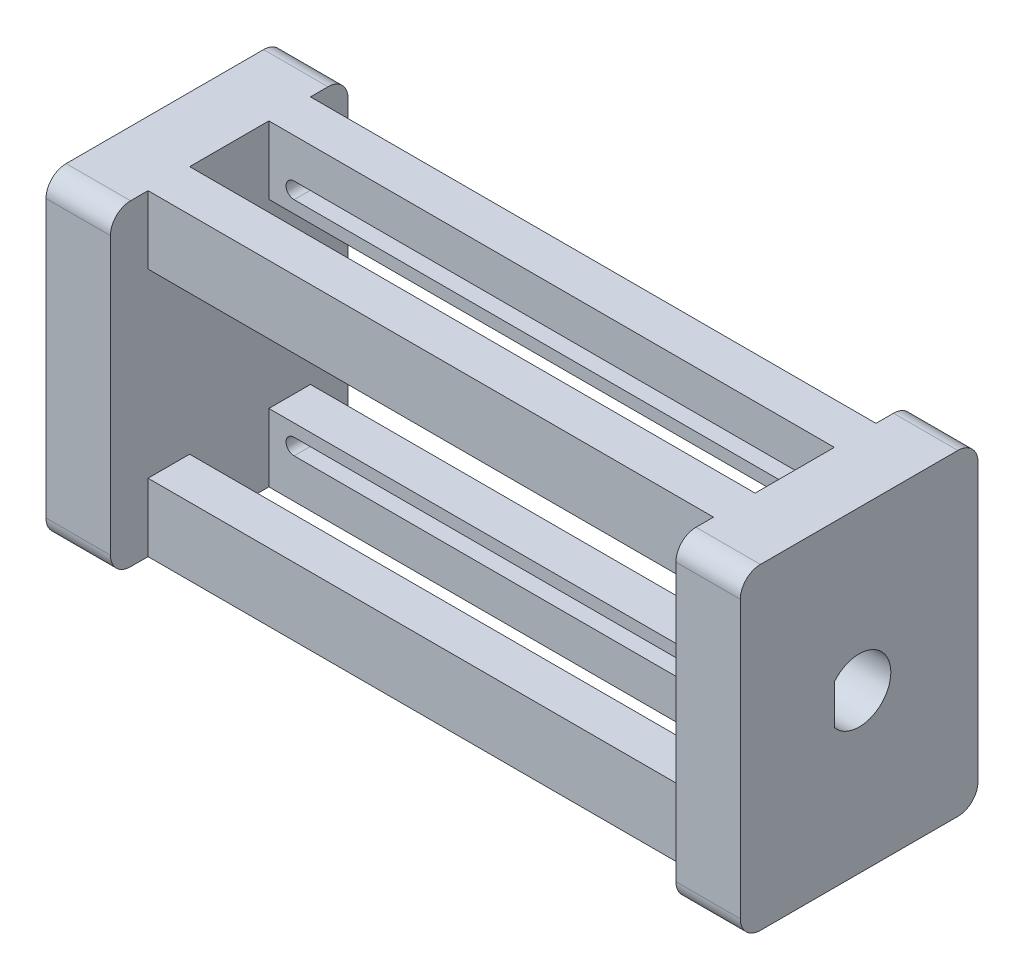
from build123d import *

# Parameters (mm, degrees)
SKETCH1_W               = 80
SKETCH1_H               = 40
BOSS_EXTRUDE1_DEPTH     = 20.5
SKETCH2_W               = 66.73316624
SKETCH2_H               = 22.854
CUT_EXTRUDE1_DEPTH      = 21.5
SKETCH3_W               = 30
SKETCH3_H               = 40
BOSS_EXTRUDE2_DEPTH     = 3.81
SKETCH4_R               = 4
CUT_EXTRUDE2_DEPTH      = 5.87375
SKETCH6_W               = 66.73316624
SKETCH6_H               = 10
CUT_EXTRUDE4_DEPTH      = 32.427
CUT_EXTRUDE4_DEPTH_BACK = 9.573
FILLET4_R               = 2.54
CUT_EXTRUDE5_DEPTH      = 5.25
BOSS_EXTRUDE3_DEPTH     = 5.87375
BOSS_EXTRUDE4_DEPTH     = 5.87375
CUT_EXTRUDE6_DEPTH      = 2.823417
CUT_EXTRUDE7_DEPTH      = 2.823417
BOSS_EXTRUDE5_DEPTH     = 0.508
BOSS_EXTRUDE6_DEPTH     = 0.508


with BuildPart() as part:
    # Sketch1 → Boss-Extrude1 (new body)
    with BuildSketch(Plane.XY):
        Rectangle(SKETCH1_W, SKETCH1_H)
    extrude(amount=BOSS_EXTRUDE1_DEPTH)

    # Sketch2 → Cut-Extrude1 (cut, through all)
    with BuildSketch(Plane.XY.offset(20.5)):
        Rectangle(SKETCH2_W, SKETCH2_H)
    extrude(amount=-CUT_EXTRUDE1_DEPTH, mode=Mode.SUBTRACT)

    # Sketch3 → Boss-Extrude2 (add, symmetric)
    with BuildSketch(Plane(origin=(40, 0, 0), x_dir=(0, 0, -1), z_dir=(1, 0, 0))):
        with Locations((-10.25, 0)):
            Rectangle(SKETCH3_W, SKETCH3_H)
    boss_extrude2 = extrude(amount=BOSS_EXTRUDE2_DEPTH, both=True)

    # Mirror1: Boss-Extrude2 across plane
    add(boss_extrude2.mirror(Plane(origin=(0, 0, 0), x_dir=(0, 0, 1), z_dir=(1, 0, 0))))

    # Sketch4 → Cut-Extrude2 (cut)
    with BuildSketch(Plane(origin=(43.81, 0, 0), x_dir=(0, 0, -1), z_dir=(1, 0, 0))):
        with Locations((-10.25, 0)):
            Circle(SKETCH4_R)
    cut_extrude2 = extrude(amount=-CUT_EXTRUDE2_DEPTH, mode=Mode.SUBTRACT)

    # Mirror2: Cut-Extrude2 across plane
    add(cut_extrude2.mirror(Plane(origin=(0, 0, 0), x_dir=(0, 0, 1), z_dir=(1, 0, 0))), mode=Mode.SUBTRACT)

    # Sketch6 → Cut-Extrude4 (cut, two sides)
    with BuildSketch(Plane(origin=(0, -11.427, 0), x_dir=(1, 0, 0), z_dir=(0, 1, 0))) as cut_extrude4_sk:
        with Locations((0, -10.25)):
            Rectangle(SKETCH6_W, SKETCH6_H)
    extrude(amount=CUT_EXTRUDE4_DEPTH, mode=Mode.SUBTRACT)
    extrude(cut_extrude4_sk.sketch, amount=-CUT_EXTRUDE4_DEPTH_BACK, mode=Mode.SUBTRACT)

    # Fillet4
    fillet4_edges = [part.edges().sort_by_distance(p)[0] for p in [
        (40, 20, 25.25),
        (40, -20, 25.25),
        (40, -20, -4.75),
        (40, 20, -4.75),
        (-40, -20, 25.25),
        (-40, 20, 25.25),
        (-40, 20, -4.75),
        (-40, -20, -4.75),
    ]]
    fillet(fillet4_edges, radius=FILLET4_R)

    # Sketch7 → Cut-Extrude5 (cut)
    with BuildSketch(Plane(origin=(0, 0, 0), x_dir=(-1, 0, 0), z_dir=(0, 0, -1))):
        with BuildLine():
            Line((-32.5, 15.016), (32.5, 15.016))
            ThreePointArc((32.5, 15.016), (33.516, 14), (32.5, 12.984))
            Line((32.5, 12.984), (-32.5, 12.984))
            ThreePointArc((-32.5, 12.984), (-33.516, 14), (-32.5, 15.016))
        make_face()
    cut_extrude5 = extrude(amount=-CUT_EXTRUDE5_DEPTH, mode=Mode.SUBTRACT)

    # Mirror3: Cut-Extrude5 across plane
    add(cut_extrude5.mirror(Plane.ZX), mode=Mode.SUBTRACT)

    # Sketch8 → Boss-Extrude3 (add)
    with BuildSketch(Plane(origin=(43.81, 0, 0), x_dir=(0, 0, -1), z_dir=(1, 0, 0))):
        with BuildLine():
            Line((-13.340048543, 2.54), (-13.340048543, -2.54))
            ThreePointArc((-13.340048543, -2.54), (-14.25, 0), (-13.340048543, 2.54))
        make_face()
    extrude(amount=-BOSS_EXTRUDE3_DEPTH)

    # Sketch9 → Boss-Extrude4 (add)
    with BuildSketch(Plane.ZY.offset(43.81)):
        with BuildLine():
            Line((13.340048543, 2.54), (13.340048543, -2.54))
            ThreePointArc((13.340048543, -2.54), (14.25, 0), (13.340048543, 2.54))
        make_face()
    extrude(amount=-BOSS_EXTRUDE4_DEPTH)

    # Sketch10 → Cut-Extrude6 (cut)
    with BuildSketch(Plane.ZY.offset(-33.36658312)):
        Polygon((20.5, 11.427), (15.25, 11.427), (15.25, 20), (5.25, 20), (5.25, 14.53036751), (5.25, 13.46963249), (5.25, 11.427), (0, 11.427), (0, -11.427), (5.25, -11.427), (5.25, -13.46963249), (5.25, -14.53036751), (5.25, -20), (15.25, -20), (15.25, -11.427), (20.5, -11.427), align=None)
    extrude(amount=-CUT_EXTRUDE6_DEPTH, mode=Mode.SUBTRACT)

    # Sketch11 → Cut-Extrude7 (cut)
    with BuildSketch(Plane(origin=(-33.36658312, 0, 0), x_dir=(0, 0, -1), z_dir=(1, 0, 0))):
        Polygon((-20.5, -11.427), (-15.25, -11.427), (-15.25, -20), (-5.25, -20), (-5.25, -14.53036751), (-5.25, -13.46963249), (-5.25, -11.427), (0, -11.427), (0, 11.427), (-5.25, 11.427), (-5.25, 13.46963249), (-5.25, 14.53036751), (-5.25, 20), (-15.25, 20), (-15.25, 11.427), (-20.5, 11.427), align=None)
    extrude(amount=-CUT_EXTRUDE7_DEPTH, mode=Mode.SUBTRACT)

    # Sketch12 → Boss-Extrude5 (add)
    with BuildSketch(Plane.ZY.offset(-36.19)):
        with BuildLine():
            Line((-4.75, 17.46), (-4.75, -17.46))
            ThreePointArc((-4.75, -17.46), (-4.006051224, -19.256051224), (-2.21, -20))
            Line((-2.21, -20), (0, -20))
            Line((0, -20), (0, -11.427))
            Line((0, -11.427), (5.25, -11.427))
            Line((5.25, -11.427), (5.25, -20))
            Line((5.25, -20), (15.25, -20))
            Line((15.25, -20), (15.25, -11.427))
            Line((15.25, -11.427), (20.5, -11.427))
            Line((20.5, -11.427), (20.5, -20))
            Line((20.5, -20), (22.71, -20))
            ThreePointArc((22.71, -20), (24.506051224, -19.256051224), (25.25, -17.46))
            Line((25.25, -17.46), (25.25, 17.46))
            ThreePointArc((25.25, 17.46), (24.506051224, 19.256051224), (22.71, 20))
            Line((22.71, 20), (20.5, 20))
            Line((20.5, 20), (20.5, 11.427))
            Line((20.5, 11.427), (15.25, 11.427))
            Line((15.25, 11.427), (15.25, 20))
            Line((15.25, 20), (5.25, 20))
            Line((5.25, 20), (5.25, 11.427))
            Line((5.25, 11.427), (0, 11.427))
            Line((0, 11.427), (0, 20))
            Line((0, 20), (-2.21, 20))
            ThreePointArc((-2.21, 20), (-4.006051224, 19.256051224), (-4.75, 17.46))
        make_face()
    extrude(amount=BOSS_EXTRUDE5_DEPTH)

    # Sketch13 → Boss-Extrude6 (add)
    with BuildSketch(Plane(origin=(-36.19, 0, 0), x_dir=(0, 0, -1), z_dir=(1, 0, 0))):
        with BuildLine():
            Line((0, -20), (2.21, -20))
            ThreePointArc((2.21, -20), (4.006051224, -19.256051224), (4.75, -17.46))
            Line((4.75, -17.46), (4.75, 17.46))
            ThreePointArc((4.75, 17.46), (4.006051224, 19.256051224), (2.21, 20))
            Line((2.21, 20), (0, 20))
            Line((0, 20), (0, 11.427))
            Line((0, 11.427), (-5.25, 11.427))
            Line((-5.25, 11.427), (-5.25, 20))
            Line((-5.25, 20), (-15.25, 20))
            Line((-15.25, 20), (-15.25, 11.427))
            Line((-15.25, 11.427), (-20.5, 11.427))
            Line((-20.5, 11.427), (-20.5, 20))
            Line((-20.5, 20), (-22.71, 20))
            ThreePointArc((-22.71, 20), (-24.506051224, 19.256051224), (-25.25, 17.46))
            Line((-25.25, 17.46), (-25.25, -17.46))
            ThreePointArc((-25.25, -17.46), (-24.506051224, -19.256051224), (-22.71, -20))
            Line((-22.71, -20), (-20.5, -20))
            Line((-20.5, -20), (-20.5, -11.427))
            Line((-20.5, -11.427), (-15.25, -11.427))
            Line((-15.25, -11.427), (-15.25, -20))
            Line((-15.25, -20), (-5.25, -20))
            Line((-5.25, -20), (-5.25, -11.427))
            Line((-5.25, -11.427), (0, -11.427))
            Line((0, -11.427), (0, -20))
        make_face()
    extrude(amount=BOSS_EXTRUDE6_DEPTH)


solid = part.part
